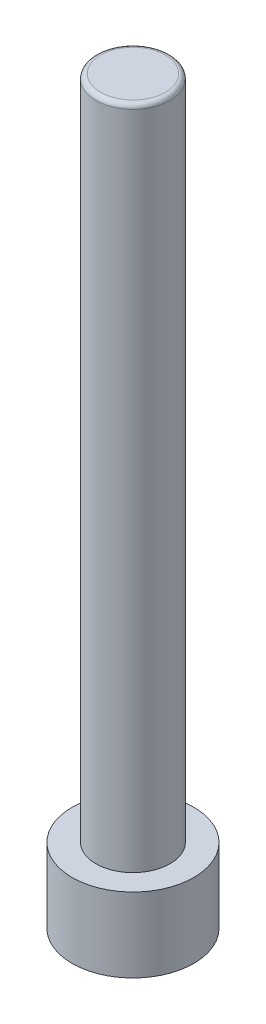
from build123d import *

# Parameters (mm, degrees)
SKETCH1_R           = 6.4
BOSS_EXTRUDE1_DEPTH = 77.83
SKETCH2_OUTSIDE_W   = 30.782
SKETCH2_OUTSIDE_H   = 30.782
SKETCH2_OUTSIDE_R   = 3.9
CUT_EXTRUDE1_DEPTH  = 70
CUT_EXTRUDE2_DEPTH  = 5.64
FILLET1_R           = 0.5


with BuildPart() as part:
    # Sketch1 → Boss-Extrude1 (new body)
    with BuildSketch(Plane(origin=(0, 0, 0), x_dir=(1, 0, 0), z_dir=(0, 1, 0))):
        Circle(SKETCH1_R)
    extrude(amount=BOSS_EXTRUDE1_DEPTH)

    # Sketch2 outside → Cut-Extrude1 (cut)
    with BuildSketch(Plane(origin=(0, 77.83, 0), x_dir=(1, 0, 0), z_dir=(0, 1, 0))):
        Rectangle(SKETCH2_OUTSIDE_W, SKETCH2_OUTSIDE_H)
        Circle(SKETCH2_OUTSIDE_R, mode=Mode.SUBTRACT)
    extrude(amount=-CUT_EXTRUDE1_DEPTH, mode=Mode.SUBTRACT)

    # Sketch8 → Cut-Extrude2 (cut)
    with BuildSketch(Plane.XZ):
        Polygon((3.464101615, 0), (1.732050808, 3), (-1.732050808, 3), (-3.464101615, 0), (-1.732050808, -3), (1.732050808, -3), align=None)
    extrude(amount=-CUT_EXTRUDE2_DEPTH, mode=Mode.SUBTRACT)

    # Fillet1
    fillet1_edges = [part.edges().sort_by_distance(p)[0] for p in [
        (-3.9, 77.83, 0),
    ]]
    fillet(fillet1_edges, radius=FILLET1_R)


solid = part.part
